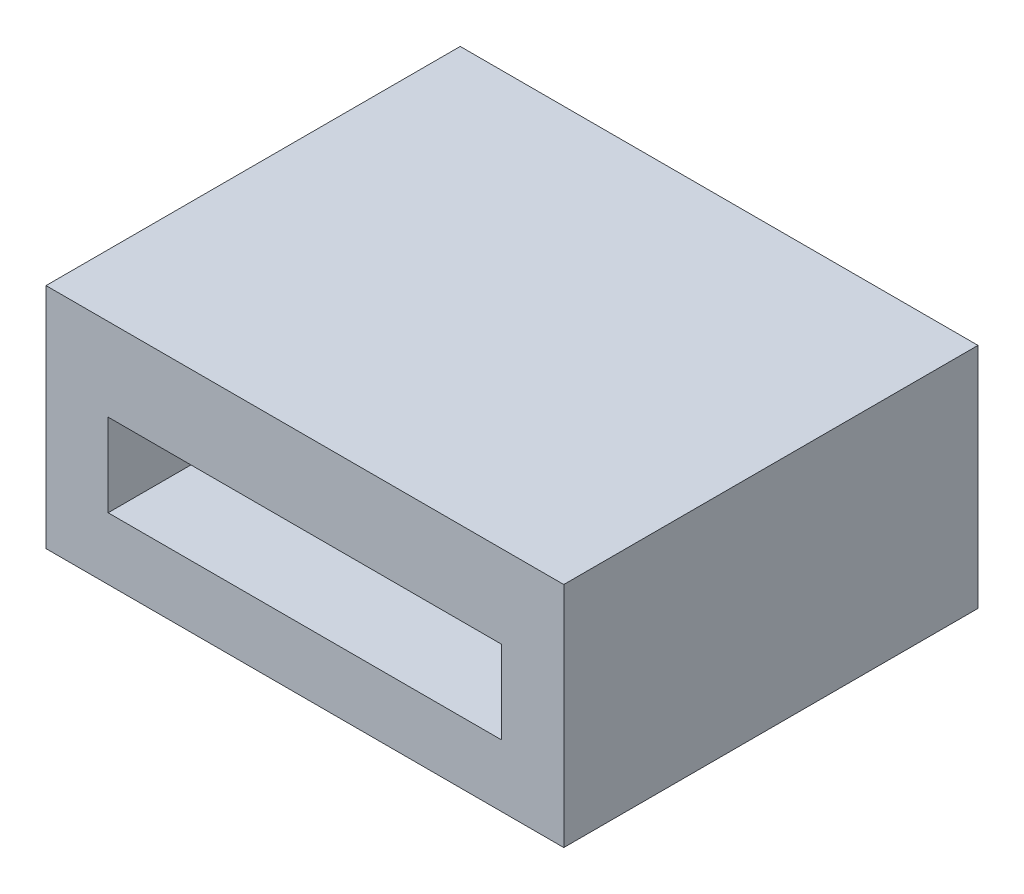
from build123d import *

# Parameters (mm, degrees)
SKETCH1_W           = 25
SKETCH1_H           = 20
BOSS_EXTRUDE1_DEPTH = 3
SKETCH2_W           = 3
SKETCH2_H           = 20
BOSS_EXTRUDE2_DEPTH = 4
SKETCH3_W           = 25
SKETCH3_H           = 20
BOSS_EXTRUDE3_DEPTH = 4


with BuildPart() as part:
    # Sketch1 → Boss-Extrude1 (new body)
    with BuildSketch(Plane(origin=(0, 0, 0), x_dir=(1, 0, 0), z_dir=(0, 1, 0))):
        with Locations((12.5, 10)):
            Rectangle(SKETCH1_W, SKETCH1_H)
    extrude(amount=BOSS_EXTRUDE1_DEPTH)

    # Sketch2 → Boss-Extrude2 (add)
    with BuildSketch(Plane(origin=(0, 3, 0), x_dir=(1, 0, 0), z_dir=(0, 1, 0))):
        with Locations((1.5, 10)):
            Rectangle(SKETCH2_W, SKETCH2_H)
        with Locations((23.5, 10)):
            Rectangle(SKETCH2_W, SKETCH2_H)
    extrude(amount=BOSS_EXTRUDE2_DEPTH)

    # Sketch3 → Boss-Extrude3 (add)
    with BuildSketch(Plane(origin=(0, 7, 0), x_dir=(1, 0, 0), z_dir=(0, 1, 0))):
        with Locations((12.5, 10)):
            Rectangle(SKETCH3_W, SKETCH3_H)
    extrude(amount=BOSS_EXTRUDE3_DEPTH)


solid = part.part
